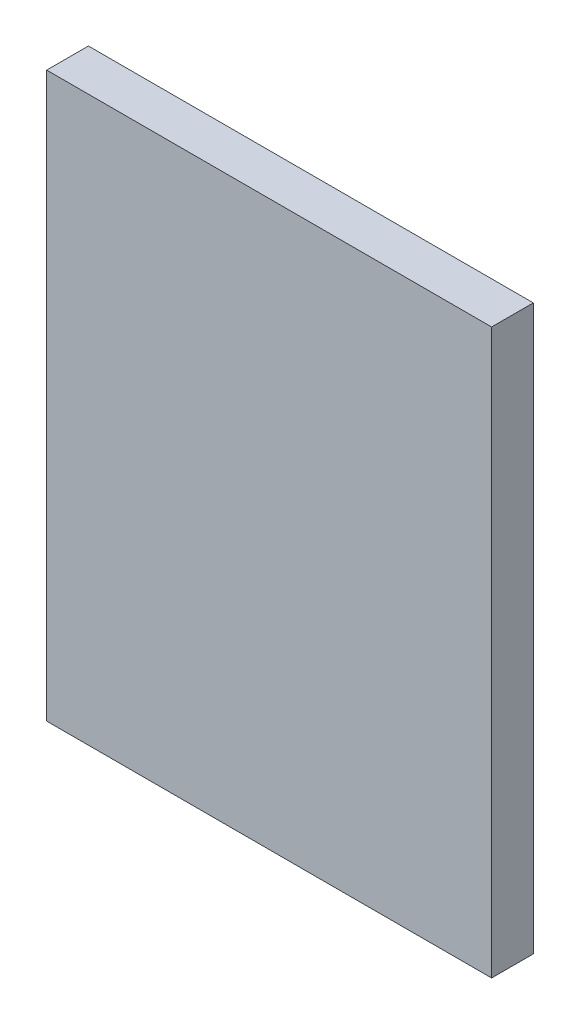
from build123d import *

# Parameters (mm, degrees)
SKETCH1_W           = 32
SKETCH1_H           = 40.55
BOSS_EXTRUDE1_DEPTH = 3


with BuildPart() as part:
    # Sketch1 → Boss-Extrude1 (new body)
    with BuildSketch(Plane.XY):
        with Locations((16, 20.275)):
            Rectangle(SKETCH1_W, SKETCH1_H)
    extrude(amount=BOSS_EXTRUDE1_DEPTH)


solid = part.part
